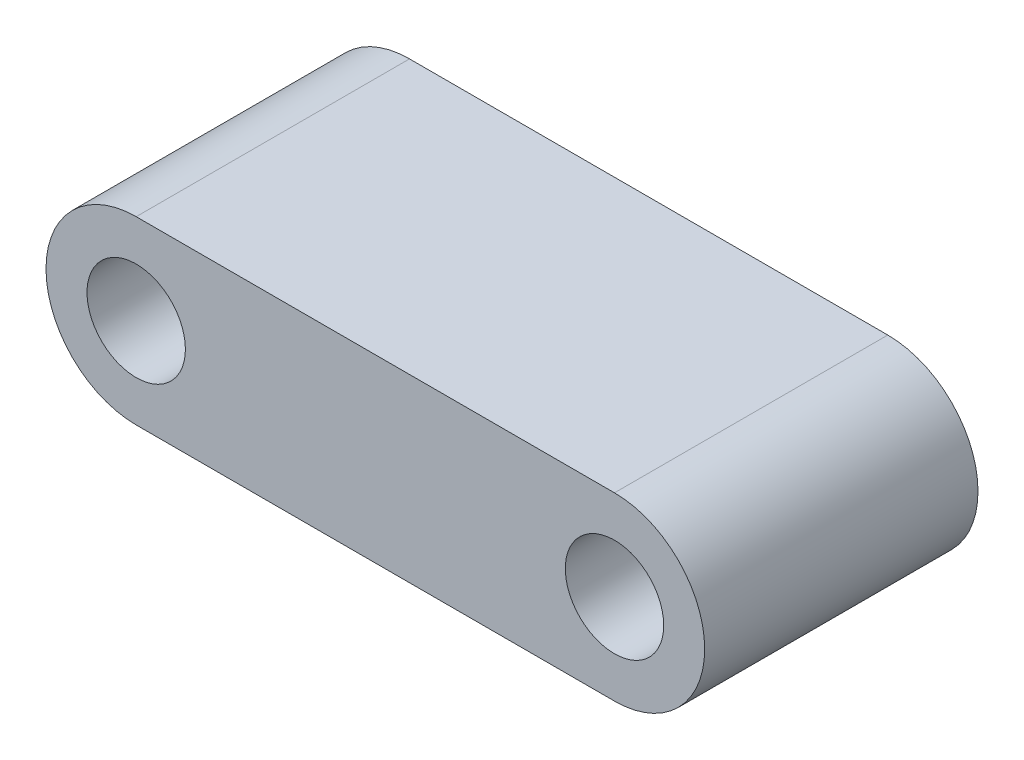
from build123d import *

# Parameters (mm, degrees)
SALIENTE_EXTRUIR1_DEPTH      = 10
TALADRO_DE_MARGEN_PARA_M31_D = 3.6


with BuildPart() as part:
    # Croquis1 → Saliente-Extruir1 (new body)
    with BuildSketch(Plane.XY):
        with BuildLine():
            Line((-7.6, 3.3), (9.9, 3.3))
            ThreePointArc((9.9, 3.3), (13.2, 0), (9.9, -3.3))
            Line((9.9, -3.3), (-7.6, -3.3))
            ThreePointArc((-7.6, -3.3), (-10.9, 0), (-7.6, 3.3))
        make_face()
    extrude(amount=SALIENTE_EXTRUIR1_DEPTH)

    # Taladro de margen para M31 (through all)
    with Locations(Plane.XY.offset(10)):
        with Locations((-7.6, 0), (9.9, 0)):
            Hole(TALADRO_DE_MARGEN_PARA_M31_D / 2)


solid = part.part
